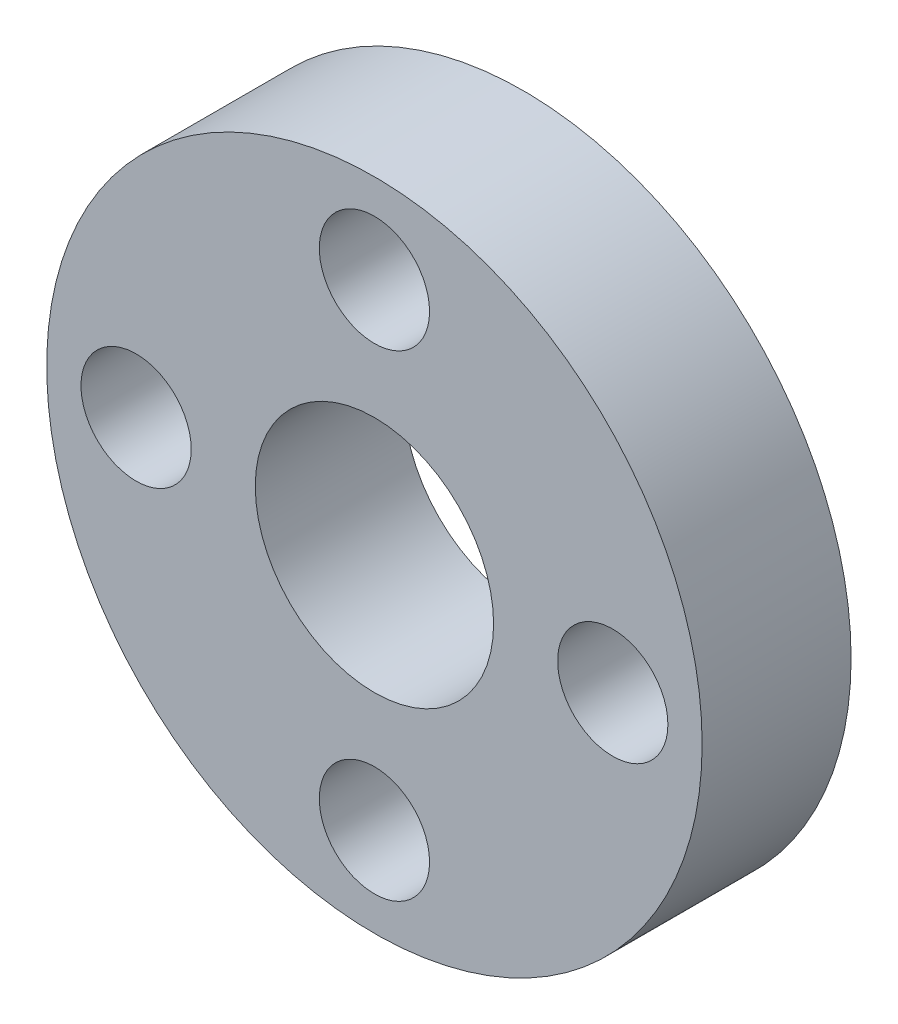
from build123d import *

# Parameters (mm, degrees)
SKETCH1_R           = 11
SKETCH1_R_2         = 1.85
SKETCH1_R_3         = 4
BOSS_EXTRUDE1_DEPTH = 5


with BuildPart() as part:
    # Sketch1 → Boss-Extrude1 (new body)
    with BuildSketch(Plane.XY):
        Circle(SKETCH1_R)
        with Locations((-8, 0)):
            Circle(SKETCH1_R_2, mode=Mode.SUBTRACT)
        with Locations((0, -8)):
            Circle(SKETCH1_R_2, mode=Mode.SUBTRACT)
        with Locations((8, 0)):
            Circle(SKETCH1_R_2, mode=Mode.SUBTRACT)
        with Locations((0, 8)):
            Circle(SKETCH1_R_2, mode=Mode.SUBTRACT)
        Circle(SKETCH1_R_3, mode=Mode.SUBTRACT)
    extrude(amount=BOSS_EXTRUDE1_DEPTH)


solid = part.part
